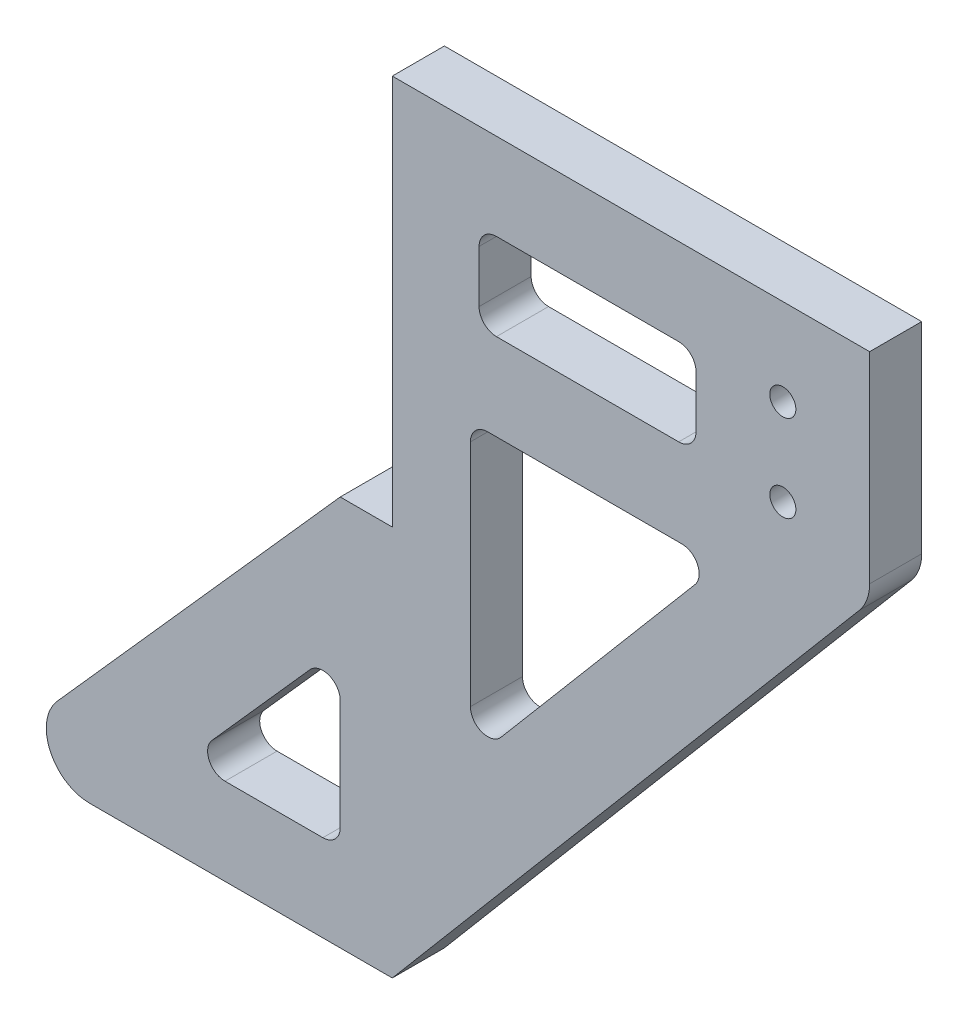
from build123d import *

# Parameters (mm, degrees)
BOSS_EXTRUDE1_DEPTH     = 6
SKETCH4_R               = 1.5
SKETCH4_W               = 25
SKETCH4_H               = 10
CUT_EXTRUDE2_DEPTH      = 1
CUT_EXTRUDE2_DEPTH_BACK = 7
FILLET1_R               = 2
FILLET2_R               = 2
FILLET3_R               = 5


with BuildPart() as part:
    # Sketch1 → Boss-Extrude1 (new body)
    with BuildSketch(Plane.XY):
        Polygon((0, 0), (55, 0), (55, -25), (0, -90), (-46, -90), (-6, -45), (0, -45), align=None)
    extrude(amount=BOSS_EXTRUDE1_DEPTH)

    # Sketch4 → Cut-Extrude2 (cut, two sides)
    with BuildSketch(Plane.XY.offset(6)) as cut_extrude2_sk:
        with Locations((45, -20)):
            Circle(SKETCH4_R)
        with Locations((45, -10)):
            Circle(SKETCH4_R)
        Polygon((9, -30), (9, -63.882376031), (37.669702795, -30), align=None)
        Polygon((-6, -60.051993223), (-23.731561579, -80), (-6, -80), align=None)
        with Locations((22.5, -15)):
            Rectangle(SKETCH4_W, SKETCH4_H)
    extrude(amount=CUT_EXTRUDE2_DEPTH, mode=Mode.SUBTRACT)
    extrude(cut_extrude2_sk.sketch, amount=-CUT_EXTRUDE2_DEPTH_BACK, mode=Mode.SUBTRACT)

    # Fillet1
    fillet1_edges = [part.edges().sort_by_distance(p)[0] for p in [
        (-6, -60.051993223, 3),
        (-6, -80, 3),
        (-23.731561579, -80, 3),
        (10, -20, 3),
        (10, -10, 3),
        (35, -10, 3),
        (35, -20, 3),
    ]]
    fillet(fillet1_edges, radius=FILLET1_R)

    # Fillet2
    fillet2_edges = [part.edges().sort_by_distance(p)[0] for p in [
        (9, -30, 3),
        (37.669702795, -30, 3),
        (9, -63.882376031, 3),
    ]]
    fillet(fillet2_edges, radius=FILLET2_R)

    # Fillet3
    fillet3_edges = [part.edges().sort_by_distance(p)[0] for p in [
        (55, -25, 3),
        (-46, -90, 3),
    ]]
    fillet(fillet3_edges, radius=FILLET3_R)


solid = part.part
